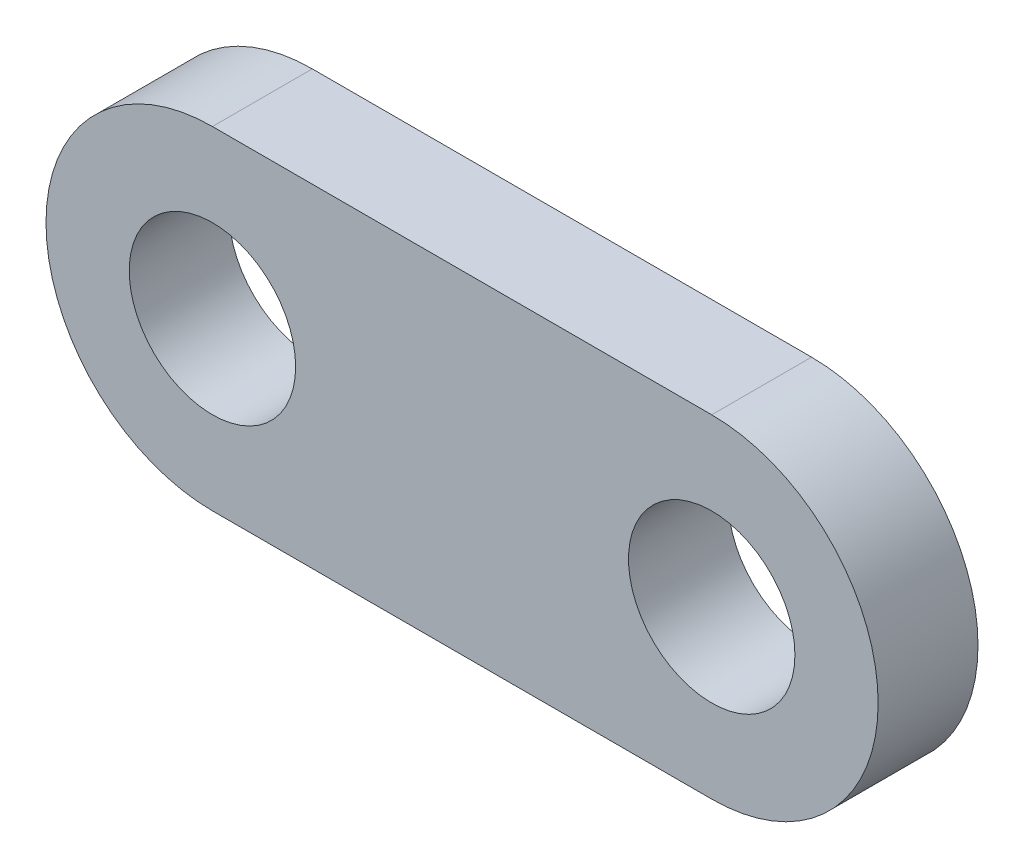
from build123d import *

# Parameters (mm, degrees)
SKETCH1_R           = 2.5
BOSS_EXTRUDE1_DEPTH = 3


with BuildPart() as part:
    # Sketch1 → Boss-Extrude1 (new body)
    with BuildSketch(Plane.XY):
        with BuildLine():
            Line((-7.5, 5), (7.5, 5))
            ThreePointArc((7.5, 5), (12.5, 0), (7.5, -5))
            Line((7.5, -5), (-7.5, -5))
            ThreePointArc((-7.5, -5), (-12.5, 0), (-7.5, 5))
        make_face()
        with Locations((7.5, 0)):
            Circle(SKETCH1_R, mode=Mode.SUBTRACT)
        with Locations((-7.5, 0)):
            Circle(SKETCH1_R, mode=Mode.SUBTRACT)
    extrude(amount=BOSS_EXTRUDE1_DEPTH)


solid = part.part
